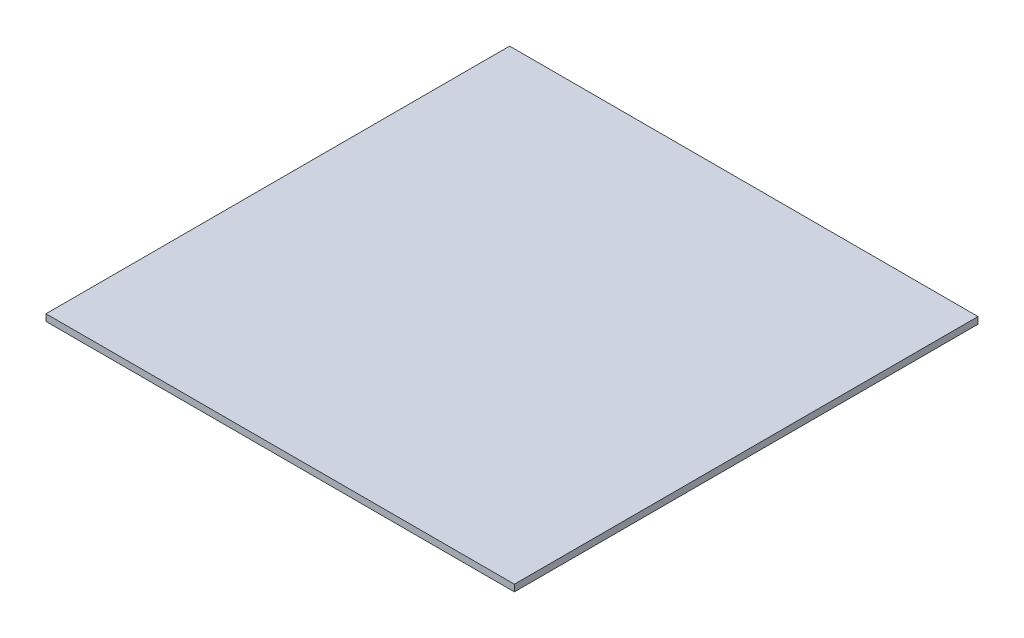
from build123d import *

# Parameters (mm, degrees)
BOSS_EXTRUDE1_DEPTH = 10


with BuildPart() as part:
    # Sketch1 → Boss-Extrude1 (new body)
    with BuildSketch(Plane(origin=(0, 0, 0), x_dir=(1, 0, 0), z_dir=(0, 1, 0))):
        Polygon((100, -173.205080757), (200, 0), (100, 173.205080757), (-100, 173.205080757), (-200, 0), (-100, -173.205080757), align=None)
        Polygon((400, 346.410161514), (200, 346.410161514), (100, 173.205080757), (200, 0), (400, 0), (500, 173.205080757), align=None)
        Polygon((500, -173.205080757), (400, 0), (200, 0), (100, -173.205080757), (200, -346.410161514), (400, -346.410161514), align=None)
        Polygon((-200, 346.410161514), (200, 346.410161514), (100, 173.205080757), (-100, 173.205080757), (-200, 0), align=None)
        Polygon((-100, -173.205080757), (-200, 0), (-200, -346.410161514), (200, -346.410161514), (100, -173.205080757), align=None)
        Polygon((500, 173.205080757), (400, 0), (500, -173.205080757), align=None)
        Polygon((500, 346.410161514), (400, 346.410161514), (500, 173.205080757), align=None)
        Polygon((500, -346.410161514), (500, -173.205080757), (400, -346.410161514), align=None)
    extrude(amount=BOSS_EXTRUDE1_DEPTH)


solid = part.part
